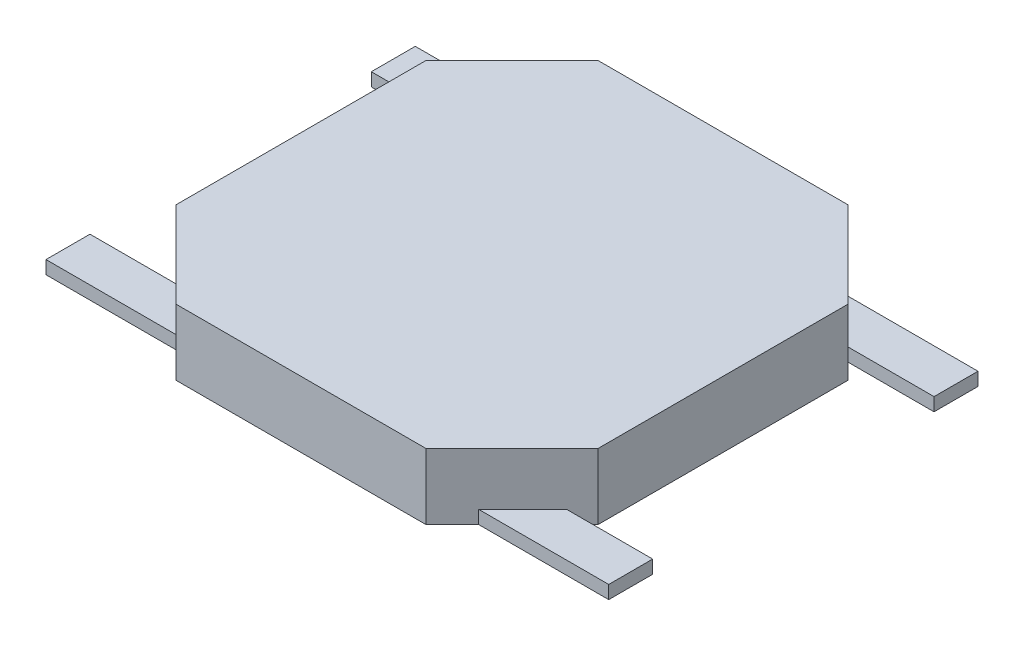
from build123d import *

# Parameters (mm, degrees)
EXTRUDE_1_DEPTH = 0.75
SKETCH_2_W      = 6.4
SKETCH_2_H      = 0.5
EXTRUDE_2_DEPTH = 0.15


with BuildPart() as part:
    # 草图1 → 凸台-拉伸1 (new body)
    with BuildSketch(Plane(origin=(0, 0, 0), x_dir=(1, 0, 0), z_dir=(0, 1, 0))):
        Polygon((-1.42, 2.4), (1.42, 2.4), (2.4, 1.42), (2.4, -1.42), (1.42, -2.4), (-1.42, -2.4), (-2.4, -1.42), (-2.4, 1.42), align=None)
    extrude(amount=EXTRUDE_1_DEPTH)

    # 草图2 → 凸台-拉伸2 (add)
    with BuildSketch(Plane.XZ):
        with Locations((0, 1.85)):
            Rectangle(SKETCH_2_W, SKETCH_2_H)
        with Locations((0, -1.85)):
            Rectangle(SKETCH_2_W, SKETCH_2_H)
    extrude(amount=-EXTRUDE_2_DEPTH)


solid = part.part
